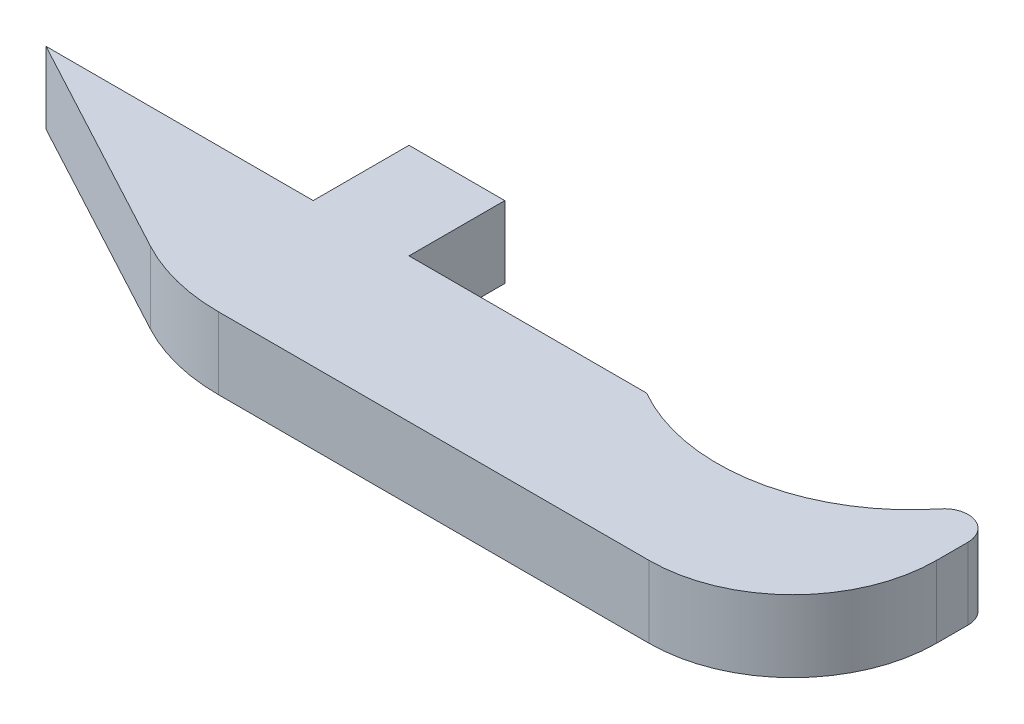
from build123d import *

# Parameters (mm, degrees)
BOSS_EXTRUDE1_DEPTH = 4.7625
FILLET1_R           = 9.525
FILLET2_R           = 1.5875
FILLET4_R           = 12.7
SKETCH2_W           = 6.35
SKETCH2_H           = 6.35
BOSS_EXTRUDE2_DEPTH = 4.7625


with BuildPart() as part:
    # Sketch1 → Boss-Extrude1 (new body)
    with BuildSketch(Plane(origin=(0, 0, 0), x_dir=(1, 0, 0), z_dir=(0, 1, 0))):
        with BuildLine():
            ThreePointArc((62.2046, 11.1252), (55.805583, 0.025067), (42.993099, 0))
            Line((42.993099, 0), (3.175, 0))
            Line((3.175, 0), (20.9296, -9.525))
            Line((20.9296, -9.525), (62.2046, -9.525))
            Line((62.2046, -9.525), (62.2046, 11.1252))
        make_face()
    extrude(amount=BOSS_EXTRUDE1_DEPTH)

    # Fillet1
    fillet1_edges = [part.edges().sort_by_distance(p)[0] for p in [
        (62.2046, 2.38125, 9.525),
    ]]
    fillet(fillet1_edges, radius=FILLET1_R)

    # Fillet2
    fillet2_edges = [part.edges().sort_by_distance(p)[0] for p in [
        (62.2046, 2.38125, -11.1252),
    ]]
    fillet(fillet2_edges, radius=FILLET2_R)

    # Fillet4
    fillet4_edges = [part.edges().sort_by_distance(p)[0] for p in [
        (20.9296, 2.38125, 9.525),
    ]]
    fillet(fillet4_edges, radius=FILLET4_R)

    # Sketch2 → Boss-Extrude2 (add)
    with BuildSketch(Plane.XZ):
        with Locations((24.0645, -3.175)):
            Rectangle(SKETCH2_W, SKETCH2_H)
    extrude(amount=-BOSS_EXTRUDE2_DEPTH)


solid = part.part
